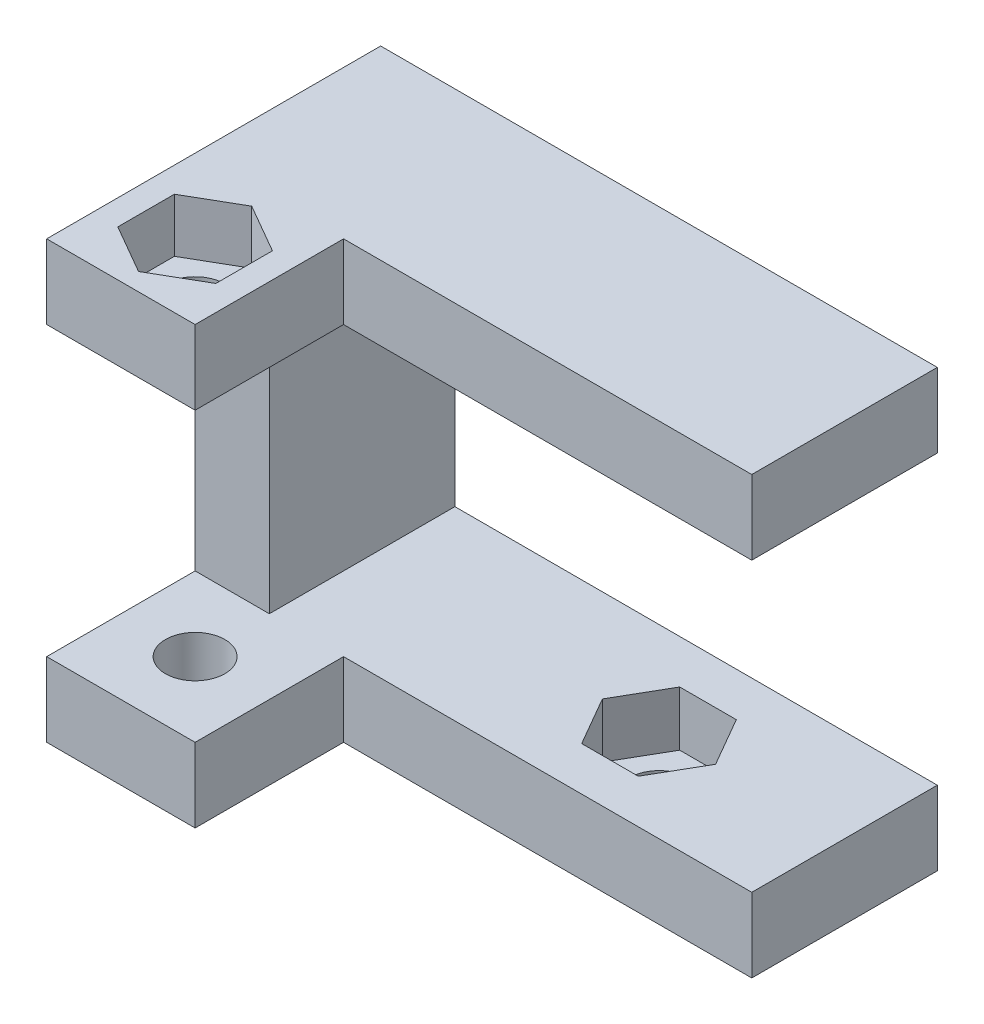
from build123d import *

# Parameters (mm, degrees)
SALIENTE_EXTRUIR1_DEPTH = 10
CORTAR_EXTRUIR2_REACH   = 6
CROQUIS3_R              = 1.6
CORTAR_EXTRUIR3_DEPTH   = 2.95
CROQUIS6_W              = 8
CROQUIS6_H              = 4
SALIENTE_EXTRUIR2_DEPTH = 8
CORTAR_EXTRUIR4_DEPTH   = 2.9
CROQUIS8_R              = 1.6
CORTAR_EXTRUIR5_DEPTH   = 24.5


with BuildPart() as part:
    # Croquis1 → Saliente-Extruir1 (new body)
    with BuildSketch(Plane.XY):
        Polygon((0, 0), (-30, 0), (-30, -23.5), (0, -23.5), (0, -19.5), (-26, -19.5), (-26, -4), (0, -4), align=None)
    extrude(amount=SALIENTE_EXTRUIR1_DEPTH)

    # Croquis3 → Cortar-Extruir2 (cut, up to next)
    with BuildSketch(Plane(origin=(0, -19.5, 0), x_dir=(1, 0, 0), z_dir=(0, 1, 0)), mode=Mode.PRIVATE) as cortar_extruir2_sk1:
        with Locations((-10, -5)):
            Circle(CROQUIS3_R)
    cortar_extruir2_tool1 = extrude(cortar_extruir2_sk1.sketch, amount=-CORTAR_EXTRUIR2_REACH, mode=Mode.PRIVATE) & part.part
    add(cortar_extruir2_tool1.solids().sort_by_distance((-10, -19.5, 5))[0], mode=Mode.SUBTRACT)

    # Croquis5 → Cortar-Extruir3 (cut)
    with BuildSketch(Plane(origin=(0, -19.5, 0), x_dir=(1, 0, 0), z_dir=(0, 1, 0))):
        Polygon((-8.475, -7.641377482), (-6.95, -5), (-8.475, -2.358622518), (-11.525, -2.358622518), (-13.05, -5), (-11.525, -7.641377482), align=None)
    extrude(amount=-CORTAR_EXTRUIR3_DEPTH, mode=Mode.SUBTRACT)

    # Croquis6 → Saliente-Extruir2 (add)
    with BuildSketch(Plane.XY.offset(10)):
        with Locations((-26, -2)):
            Rectangle(CROQUIS6_W, CROQUIS6_H)
        with Locations((-26, -21.5)):
            Rectangle(CROQUIS6_W, CROQUIS6_H)
    extrude(amount=SALIENTE_EXTRUIR2_DEPTH)

    # Croquis7 → Cortar-Extruir4 (cut)
    with BuildSketch(Plane(origin=(0, 0, 0), x_dir=(1, 0, 0), z_dir=(0, 1, 0))):
        Polygon((-26, -17.05), (-23.358622518, -15.525), (-23.358622518, -12.475), (-26, -10.95), (-28.641377482, -12.475), (-28.641377482, -15.525), align=None)
    extrude(amount=-CORTAR_EXTRUIR4_DEPTH, mode=Mode.SUBTRACT)

    # Croquis8 → Cortar-Extruir5 (cut, through all)
    with BuildSketch(Plane(origin=(0, 0, 0), x_dir=(1, 0, 0), z_dir=(0, 1, 0))):
        with Locations((-26, -14)):
            Circle(CROQUIS8_R)
    extrude(amount=-CORTAR_EXTRUIR5_DEPTH, mode=Mode.SUBTRACT)


solid = part.part
